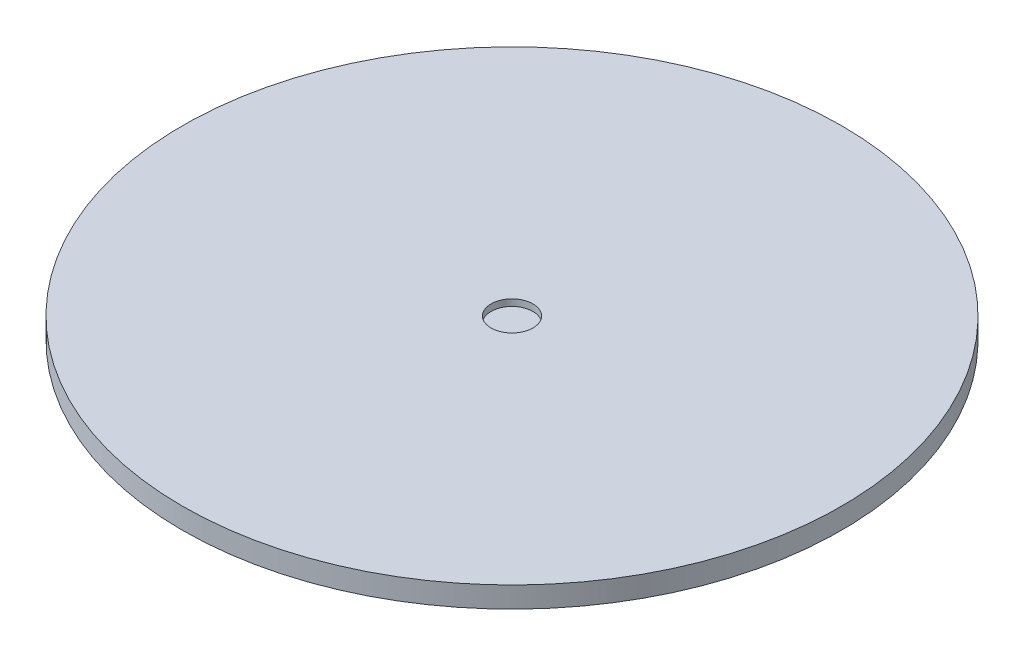
from build123d import *

# Parameters (mm, degrees)
SKETCH1_R           = 100
BOSS_EXTRUDE1_DEPTH = 6.35
SKETCH3_R           = 6.35
CUT_EXTRUDE1_DEPTH  = 2


with BuildPart() as part:
    # Sketch1 → Boss-Extrude1 (new body)
    with BuildSketch(Plane(origin=(0, 0, 0), x_dir=(1, 0, 0), z_dir=(0, 1, 0))):
        Circle(SKETCH1_R)
    extrude(amount=BOSS_EXTRUDE1_DEPTH)

    # Sketch3 → Cut-Extrude1 (cut)
    with BuildSketch(Plane(origin=(0, 6.35, 0), x_dir=(1, 0, 0), z_dir=(0, 1, 0))):
        Circle(SKETCH3_R)
    extrude(amount=-CUT_EXTRUDE1_DEPTH, mode=Mode.SUBTRACT)


solid = part.part
